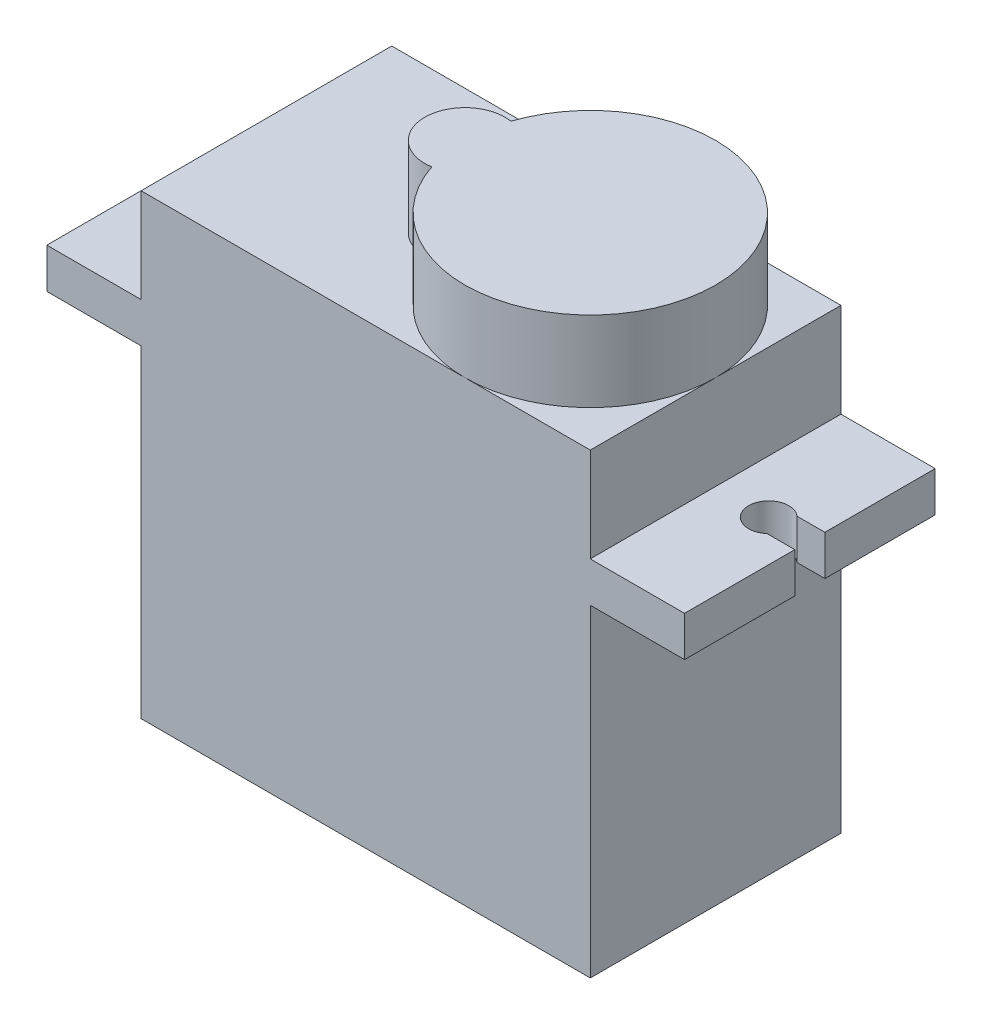
from build123d import *

# Parameters (mm, degrees)
RESSALTO_EXTRUS_O1_DEPTH = 12.5
ESBO_O2_R                = 1
CORTE_EXTRUS_O1_DEPTH    = 12.5
RESSALTO_EXTRUS_O2_DEPTH = 4


with BuildPart() as part:
    # Esboço1 → Ressalto-extrusão1 (new body)
    with BuildSketch(Plane.XY):
        Polygon((-11.2, -11.4), (11.2, -11.4), (11.2, 4.7), (15.9, 4.7), (15.9, 6.7), (11.2, 6.7), (11.2, 11.4), (-11.2, 11.4), (-11.2, 6.7), (-15.9, 6.7), (-15.9, 4.7), (-11.2, 4.7), align=None)
    extrude(amount=RESSALTO_EXTRUS_O1_DEPTH)

    # Esboço2 → Corte-extrusão1 (cut)
    with BuildSketch(Plane(origin=(0, 11.4, 0), x_dir=(1, 0, 0), z_dir=(0, 1, 0))):
        with BuildLine():
            Line((-14.511437828, -7), (-15.9, -7))
            Line((-15.9, -7), (-15.9, -5.5))
            Line((-15.9, -5.5), (-14.511437828, -5.5))
            ThreePointArc((-14.511437828, -5.5), (-12.85, -6.25), (-14.511437828, -7))
        make_face()
        with Locations((13.85, -6.25)):
            Circle(ESBO_O2_R)
        with BuildLine():
            ThreePointArc((14.85, -6.25), (14.761437828, -6.661437828), (14.511437828, -7))
            Line((14.511437828, -7), (15.9, -7))
            Line((15.9, -7), (15.9, -5.5))
            Line((15.9, -5.5), (14.511437828, -5.5))
            ThreePointArc((14.511437828, -5.5), (14.761437828, -5.838562172), (14.85, -6.25))
        make_face()
    extrude(amount=-CORTE_EXTRUS_O1_DEPTH, mode=Mode.SUBTRACT)

    # Esboço3 → Ressalto-extrusão2 (add)
    with BuildSketch(Plane(origin=(0, 11.4, 0), x_dir=(1, 0, 0), z_dir=(0, 1, 0))):
        with BuildLine():
            ThreePointArc((-0.98, -8.224234029), (11.2, -6.25), (-0.98, -4.275765971))
            ThreePointArc((-0.98, -4.275765971), (-3.3, -6.25), (-0.98, -8.224234029))
        make_face()
    extrude(amount=RESSALTO_EXTRUS_O2_DEPTH)


solid = part.part
